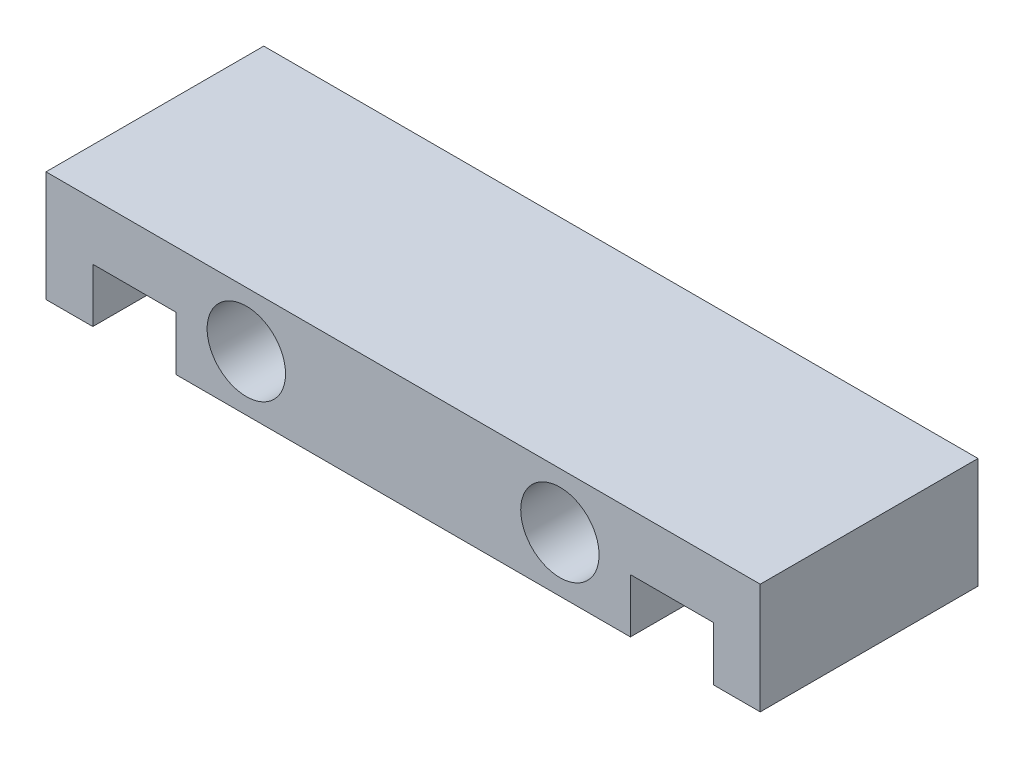
from build123d import *

# Parameters (mm, degrees)
SKETCH1_W           = 82
SKETCH1_H           = 25
BOSS_EXTRUDE1_DEPTH = 12.7
SKETCH2_W           = 9.53
SKETCH2_H           = 6.2
CUT_EXTRUDE1_DEPTH  = 26
SKETCH3_R           = 4.5
CUT_EXTRUDE2_DEPTH  = 13


with BuildPart() as part:
    # Sketch1 → Boss-Extrude1 (new body)
    with BuildSketch(Plane(origin=(0, 0, 0), x_dir=(1, 0, 0), z_dir=(0, 1, 0))):
        with Locations((41, 12.5)):
            Rectangle(SKETCH1_W, SKETCH1_H)
    extrude(amount=BOSS_EXTRUDE1_DEPTH)

    # Sketch2 → Cut-Extrude1 (cut, through all)
    with BuildSketch(Plane.XY):
        with Locations((10.14, 3.1)):
            Rectangle(SKETCH2_W, SKETCH2_H)
    cut_extrude1 = extrude(amount=-CUT_EXTRUDE1_DEPTH, mode=Mode.SUBTRACT)

    # Sketch3 → Cut-Extrude2 (cut)
    with BuildSketch(Plane.XY):
        with Locations((23, 6.35)):
            Circle(SKETCH3_R)
    cut_extrude2 = extrude(amount=-CUT_EXTRUDE2_DEPTH, mode=Mode.SUBTRACT)

    # Mirror1: Cut-Extrude1, Cut-Extrude2 across plane
    add(cut_extrude1.mirror(Plane(origin=(41, 0, 0), x_dir=(0, 0, 1), z_dir=(1, 0, 0))), mode=Mode.SUBTRACT)
    add(cut_extrude2.mirror(Plane(origin=(41, 0, 0), x_dir=(0, 0, 1), z_dir=(1, 0, 0))), mode=Mode.SUBTRACT)


solid = part.part
